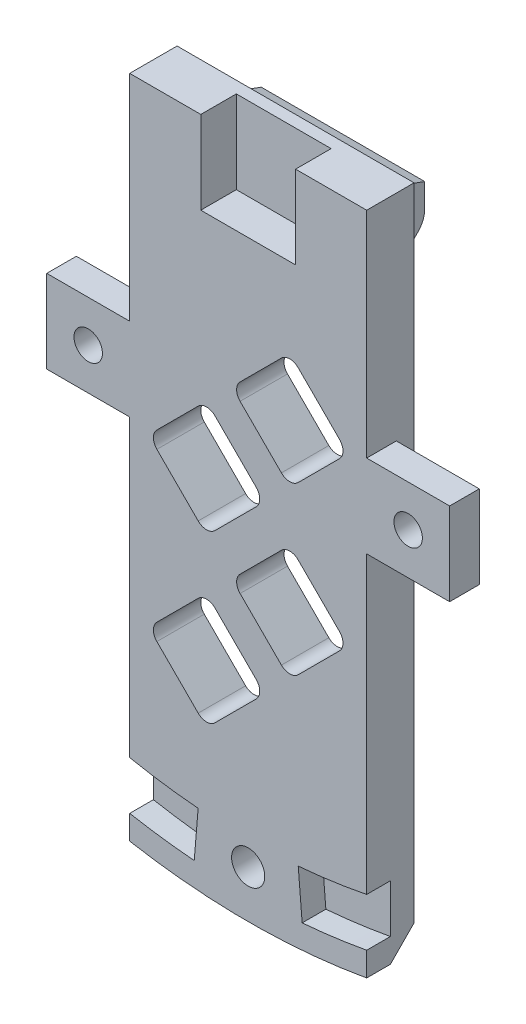
from build123d import *

# Parameters (mm, degrees)
BOSS_EXTRUDE1_DEPTH = 5.08
BOSS_EXTRUDE2_DEPTH = 8.763
CHAMFER1_SIZE       = 2.54
CUT_EXTRUDE2_DEPTH  = 6.35
SKETCH6_W           = 10.16
SKETCH6_H           = 8.89
CUT_EXTRUDE3_DEPTH  = 3.81
SKETCH7_R           = 4.953
CUT_EXTRUDE4_DEPTH  = 2.54
SKETCH8_R           = 1.786664303
SKETCH8_R_2         = 1.778
CUT_EXTRUDE5_DEPTH  = 3.54
CUT_EXTRUDE6_DEPTH  = 2.54
CUT_EXTRUDE7_DEPTH  = 0.762
SKETCH11_W          = 8.89
SKETCH11_H          = 8.89
SKETCH11_R          = 1.524
BOSS_EXTRUDE3_DEPTH = 3.175


with BuildPart() as part:
    # Sketch1 → Boss-Extrude1 (new body)
    with BuildSketch(Plane.XY):
        with BuildLine():
            Line((-12.7, 0), (-12.7, -71.267258261))
            ThreePointArc((-12.7, -71.267258261), (0, -72.39), (12.7, -71.267258261))
            Line((12.7, -71.267258261), (12.7, 0))
            Line((12.7, 0), (-12.7, 0))
        make_face()
    extrude(amount=BOSS_EXTRUDE1_DEPTH)

    # Sketch4 → Boss-Extrude2 (add, symmetric)
    with BuildSketch(Plane(origin=(0, 0, 0), x_dir=(0, 0, -1), z_dir=(1, 0, 0))):
        with BuildLine():
            Line((4.336051224, -8.725020014), (0.743948776, -12.317122463))
            ThreePointArc((0.743948776, -12.317122463), (0.193345987, -13.141157769), (0, -14.113173687))
            Line((0, -14.113173687), (0, -2.54))
            Line((0, -2.54), (5.08, -4.38896879))
            Line((5.08, -4.38896879), (5.08, -6.92896879))
            ThreePointArc((5.08, -6.92896879), (4.886654013, -7.900984708), (4.336051224, -8.725020014))
        make_face()
    extrude(amount=BOSS_EXTRUDE2_DEPTH, both=True)

    # Chamfer1
    chamfer1_edges = [part.edges().sort_by_distance(p)[0] for p in [
        (0, -72.39, 0),
    ]]
    chamfer(chamfer1_edges, length=CHAMFER1_SIZE)

    # Sketch5 → Cut-Extrude2 (cut)
    with BuildSketch(Plane(origin=(0, 0, 0), x_dir=(-1, 0, 0), z_dir=(0, 0, -1))):
        with BuildLine():
            Line((-9.788025612, -42.36132736), (-5.358068299, -46.791284673))
            ThreePointArc((-5.358068299, -46.791284673), (-4.460042687, -47.163259061), (-3.562017075, -46.791284673))
            Line((-3.562017075, -46.791284673), (0.867940238, -42.36132736))
            ThreePointArc((0.867940238, -42.36132736), (1.239914626, -41.463301747), (0.867940238, -40.565276135))
            Line((0.867940238, -40.565276135), (-3.562017075, -36.135318822))
            ThreePointArc((-3.562017075, -36.135318822), (-4.460042687, -35.763344434), (-5.358068299, -36.135318822))
            Line((-5.358068299, -36.135318822), (-9.788025612, -40.565276135))
            ThreePointArc((-9.788025612, -40.565276135), (-10.16, -41.463301747), (-9.788025612, -42.36132736))
        make_face()
        with BuildLine():
            Line((-0.867940238, -33.441241986), (3.562017075, -37.871199299))
            ThreePointArc((3.562017075, -37.871199299), (4.460042687, -38.243173687), (5.358068299, -37.871199299))
            Line((5.358068299, -37.871199299), (9.788025612, -33.441241986))
            ThreePointArc((9.788025612, -33.441241986), (10.16, -32.543216374), (9.788025612, -31.645190762))
            Line((9.788025612, -31.645190762), (5.358068299, -27.215233449))
            ThreePointArc((5.358068299, -27.215233449), (4.460042687, -26.843259061), (3.562017075, -27.215233449))
            Line((3.562017075, -27.215233449), (-0.867940238, -31.645190762))
            ThreePointArc((-0.867940238, -31.645190762), (-1.239914626, -32.543216374), (-0.867940238, -33.441241986))
        make_face()
        with BuildLine():
            Line((-9.788025612, -24.521156612), (-5.358068299, -28.951113925))
            ThreePointArc((-5.358068299, -28.951113925), (-4.460042687, -29.323088313), (-3.562017075, -28.951113925))
            Line((-3.562017075, -28.951113925), (0.867940238, -24.521156612))
            ThreePointArc((0.867940238, -24.521156612), (1.239914626, -23.623131), (0.867940238, -22.725105388))
            Line((0.867940238, -22.725105388), (-3.562017075, -18.295148075))
            ThreePointArc((-3.562017075, -18.295148075), (-4.460042687, -17.923173687), (-5.358068299, -18.295148075))
            Line((-5.358068299, -18.295148075), (-9.788025612, -22.725105388))
            ThreePointArc((-9.788025612, -22.725105388), (-10.16, -23.623131), (-9.788025612, -24.521156612))
        make_face()
        with BuildLine():
            Line((-0.867940238, -51.281412733), (3.562017075, -55.711370046))
            ThreePointArc((3.562017075, -55.711370046), (4.460042687, -56.083344434), (5.358068299, -55.711370046))
            Line((5.358068299, -55.711370046), (9.788025612, -51.281412733))
            ThreePointArc((9.788025612, -51.281412733), (10.16, -50.383387121), (9.788025612, -49.485361509))
            Line((9.788025612, -49.485361509), (5.358068299, -45.055404196))
            ThreePointArc((5.358068299, -45.055404196), (4.460042687, -44.683429808), (3.562017075, -45.055404196))
            Line((3.562017075, -45.055404196), (-0.867940238, -49.485361509))
            ThreePointArc((-0.867940238, -49.485361509), (-1.239914626, -50.383387121), (-0.867940238, -51.281412733))
        make_face()
    extrude(amount=-CUT_EXTRUDE2_DEPTH, mode=Mode.SUBTRACT)

    # Sketch6 → Cut-Extrude3 (cut)
    with BuildSketch(Plane.XY.offset(5.08)):
        with Locations((0, -4.445)):
            Rectangle(SKETCH6_W, SKETCH6_H)
    extrude(amount=-CUT_EXTRUDE3_DEPTH, mode=Mode.SUBTRACT)

    # Sketch7 → Cut-Extrude4 (cut)
    with BuildSketch(Plane(origin=(0, 0, 0), x_dir=(-1, 0, 0), z_dir=(0, 0, -1))):
        with Locations((0, -67.31)):
            Circle(SKETCH7_R)
    extrude(amount=-CUT_EXTRUDE4_DEPTH, mode=Mode.SUBTRACT)

    # Sketch8 → Cut-Extrude5 (cut, through all)
    with BuildSketch(Plane(origin=(0, 0, 2.54), x_dir=(-1, 0, 0), z_dir=(0, 0, -1))):
        Circle(SKETCH8_R)
        with Locations((0, -67.31)):
            Circle(SKETCH8_R_2)
    extrude(amount=-CUT_EXTRUDE5_DEPTH, mode=Mode.SUBTRACT)

    # Sketch9 → Cut-Extrude6 (cut)
    with BuildSketch(Plane.XY.offset(5.08)):
        with BuildLine():
            Line((-12.7, -68.685751798), (-12.7, -63.51269873))
            ThreePointArc((-12.7, -63.51269873), (-9.046553162, -64.135113439), (-5.363487601, -64.547547597))
            Line((-5.363487601, -64.547547597), (-5.784153295, -69.610100349))
            ThreePointArc((-5.784153295, -69.610100349), (-9.25362555, -69.234333348), (-12.7, -68.685751798))
        make_face()
        with BuildLine():
            Line((5.784153295, -69.610100349), (5.363487601, -64.547547597))
            ThreePointArc((5.363487601, -64.547547597), (9.046553162, -64.135113439), (12.7, -63.51269873))
            Line((12.7, -63.51269873), (12.7, -68.685751798))
            ThreePointArc((12.7, -68.685751798), (9.25362555, -69.234333348), (5.784153295, -69.610100349))
        make_face()
    extrude(amount=-CUT_EXTRUDE6_DEPTH, mode=Mode.SUBTRACT)

    # Sketch10 → Cut-Extrude7 (cut)
    with BuildSketch(Plane(origin=(0, 0, 0), x_dir=(-1, 0, 0), z_dir=(0, 0, -1))):
        with BuildLine():
            Line((-10.795, -46.742506644), (-10.795, -54.024267598))
            Line((-10.795, -54.024267598), (-8.052145135, -51.281412733))
            ThreePointArc((-8.052145135, -51.281412733), (-7.680170747, -50.383387121), (-8.052145135, -49.485361509))
            Line((-8.052145135, -49.485361509), (-10.795, -46.742506644))
        make_face()
        with BuildLine():
            Line((0.867940238, -58.405446883), (-3.562017075, -53.97548957))
            ThreePointArc((-3.562017075, -53.97548957), (-4.460042687, -53.603515182), (-5.358068299, -53.97548957))
            Line((-5.358068299, -53.97548957), (-9.788025612, -58.405446883))
            ThreePointArc((-9.788025612, -58.405446883), (-10.16, -59.303472495), (-9.788025612, -60.201498107))
            Line((-9.788025612, -60.201498107), (-7.632523719, -62.357))
            Line((-7.632523719, -62.357), (-1.287561655, -62.357))
            Line((-1.287561655, -62.357), (0.867940238, -60.201498107))
            ThreePointArc((0.867940238, -60.201498107), (1.239914626, -59.303472495), (0.867940238, -58.405446883))
        make_face()
        with BuildLine():
            Line((8.052145135, -42.36132736), (10.795, -45.104182224))
            Line((10.795, -45.104182224), (10.795, -37.822421271))
            Line((10.795, -37.822421271), (8.052145135, -40.565276135))
            ThreePointArc((8.052145135, -40.565276135), (7.680170747, -41.463301747), (8.052145135, -42.36132736))
        make_face()
        with BuildLine():
            Line((-10.795, -28.902335897), (-10.795, -36.184096851))
            Line((-10.795, -36.184096851), (-8.052145135, -33.441241986))
            ThreePointArc((-8.052145135, -33.441241986), (-7.680170747, -32.543216374), (-8.052145135, -31.645190762))
            Line((-8.052145135, -31.645190762), (-10.795, -28.902335897))
        make_face()
        with BuildLine():
            Line((9.370923164, -16.018173687), (-0.45083779, -16.018173687))
            Line((-0.45083779, -16.018173687), (3.562017075, -20.031028552))
            ThreePointArc((3.562017075, -20.031028552), (4.460042687, -20.40300294), (5.358068299, -20.031028552))
            Line((5.358068299, -20.031028552), (9.370923164, -16.018173687))
        make_face()
        with BuildLine():
            Line((8.052145135, -24.521156612), (10.795, -27.264011477))
            Line((10.795, -27.264011477), (10.795, -19.982250523))
            Line((10.795, -19.982250523), (8.052145135, -22.725105388))
            ThreePointArc((8.052145135, -22.725105388), (7.680170747, -23.623131), (8.052145135, -24.521156612))
        make_face()
        with BuildLine():
            Line((8.052145135, -60.201498107), (10.207647028, -62.357))
            Line((10.207647028, -62.357), (10.795, -62.357))
            Line((10.795, -62.357), (10.795, -55.662592018))
            Line((10.795, -55.662592018), (8.052145135, -58.405446883))
            ThreePointArc((8.052145135, -58.405446883), (7.680170747, -59.303472495), (8.052145135, -60.201498107))
        make_face()
    extrude(amount=-CUT_EXTRUDE7_DEPTH, mode=Mode.SUBTRACT)

    # Sketch11 → Boss-Extrude3 (add)
    with BuildSketch(Plane.XY.offset(5.08)):
        with Locations((17.145, -27.452258261)):
            Rectangle(SKETCH11_W, SKETCH11_H)
        with Locations((17.145, -27.452258261)):
            Circle(SKETCH11_R, mode=Mode.SUBTRACT)
        with Locations((-17.145, -27.452258261)):
            Rectangle(SKETCH11_W, SKETCH11_H)
        with Locations((-17.145, -27.452258261)):
            Circle(SKETCH11_R, mode=Mode.SUBTRACT)
    extrude(amount=-BOSS_EXTRUDE3_DEPTH)


solid = part.part
